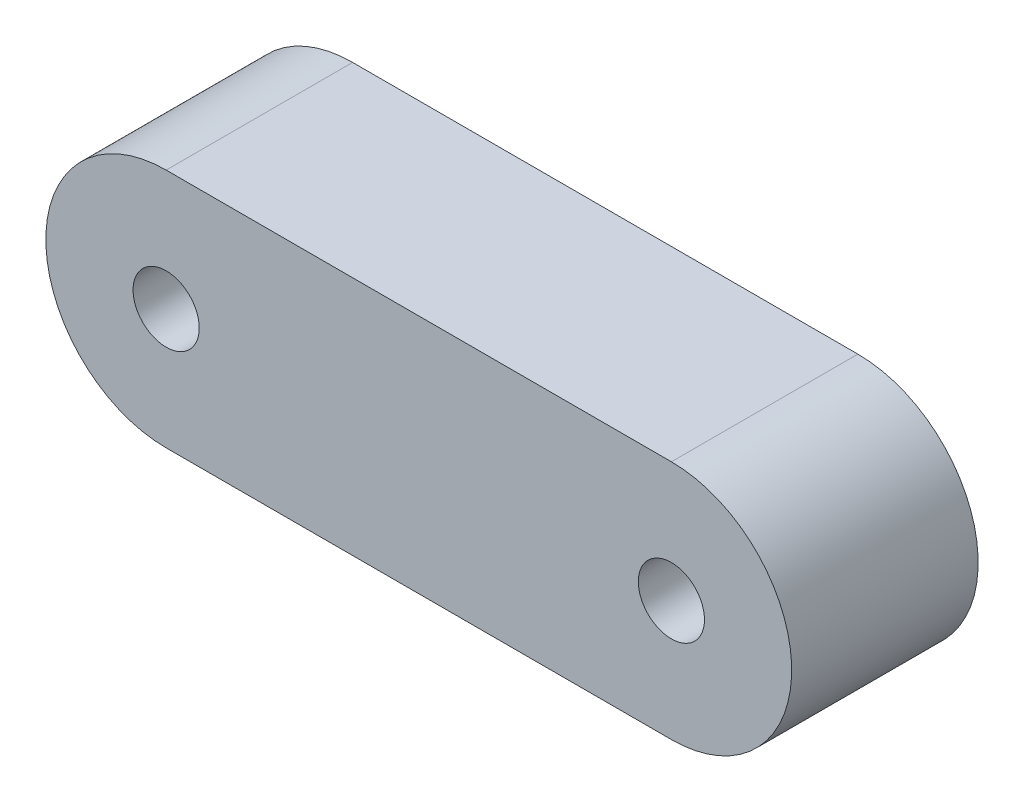
from build123d import *

# Parameters (mm, degrees)
SKETCH1_R           = 2.75
BOSS_EXTRUDE1_DEPTH = 15.5


with BuildPart() as part:
    # Sketch1 → Boss-Extrude1 (new body)
    with BuildSketch(Plane.XY):
        with BuildLine():
            Line((0, -10), (-42, -10))
            ThreePointArc((-42, -10), (-52, 0), (-42, 10))
            Line((-42, 10), (0, 10))
            ThreePointArc((0, 10), (10, 0), (0, -10))
        make_face()
        with Locations((-42, 0)):
            Circle(SKETCH1_R, mode=Mode.SUBTRACT)
        Circle(SKETCH1_R, mode=Mode.SUBTRACT)
    extrude(amount=BOSS_EXTRUDE1_DEPTH)


solid = part.part
